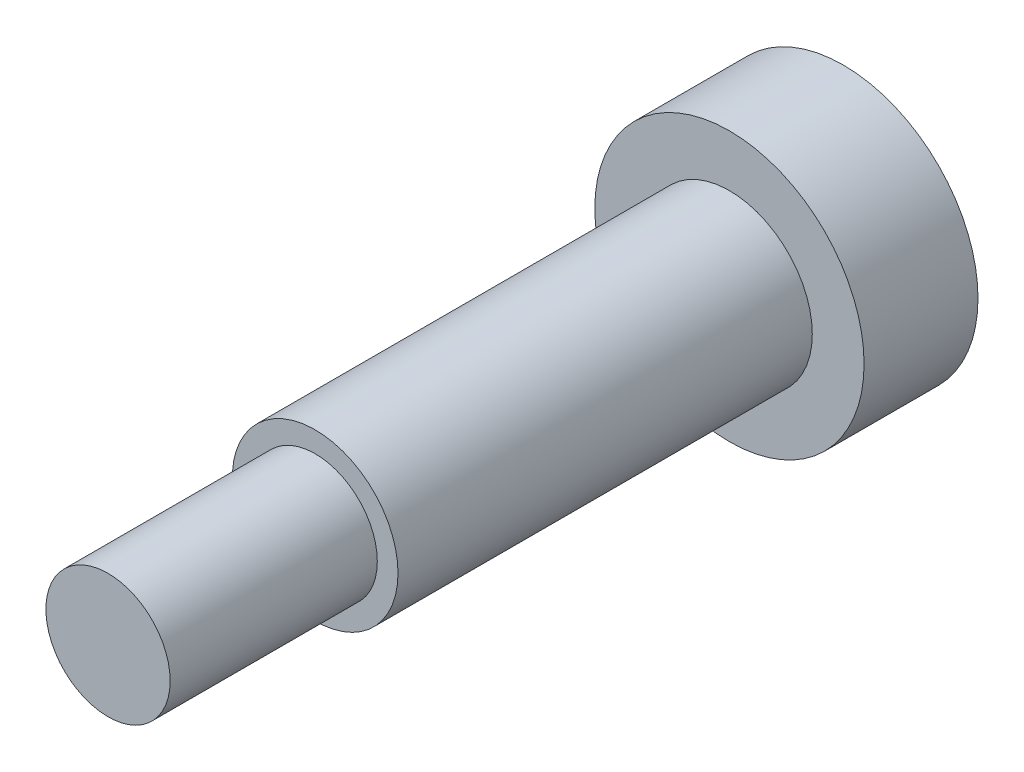
from build123d import *

# Parameters (mm, degrees)
SZKIC1_R                    = 4
DODANIE_WYCI_GNI_CIE1_DEPTH = 20
SZKIC2_R                    = 6.5
DODANIE_WYCI_GNI_CIE2_DEPTH = 5.5
SZKIC3_R                    = 3
DODANIE_WYCI_GNI_CIE3_DEPTH = 10


with BuildPart() as part:
    # Szkic1 → Dodanie-wyciągnięcie1 (new body)
    with BuildSketch(Plane.XY):
        Circle(SZKIC1_R)
    extrude(amount=DODANIE_WYCI_GNI_CIE1_DEPTH)

    # Szkic2 → Dodanie-wyciągnięcie2 (add)
    with BuildSketch(Plane(origin=(0, 0, 0), x_dir=(-1, 0, 0), z_dir=(0, 0, -1))):
        Circle(SZKIC2_R)
    extrude(amount=DODANIE_WYCI_GNI_CIE2_DEPTH)

    # Szkic3 → Dodanie-wyciągnięcie3 (add)
    with BuildSketch(Plane.XY.offset(20)):
        Circle(SZKIC3_R)
    extrude(amount=DODANIE_WYCI_GNI_CIE3_DEPTH)


solid = part.part
